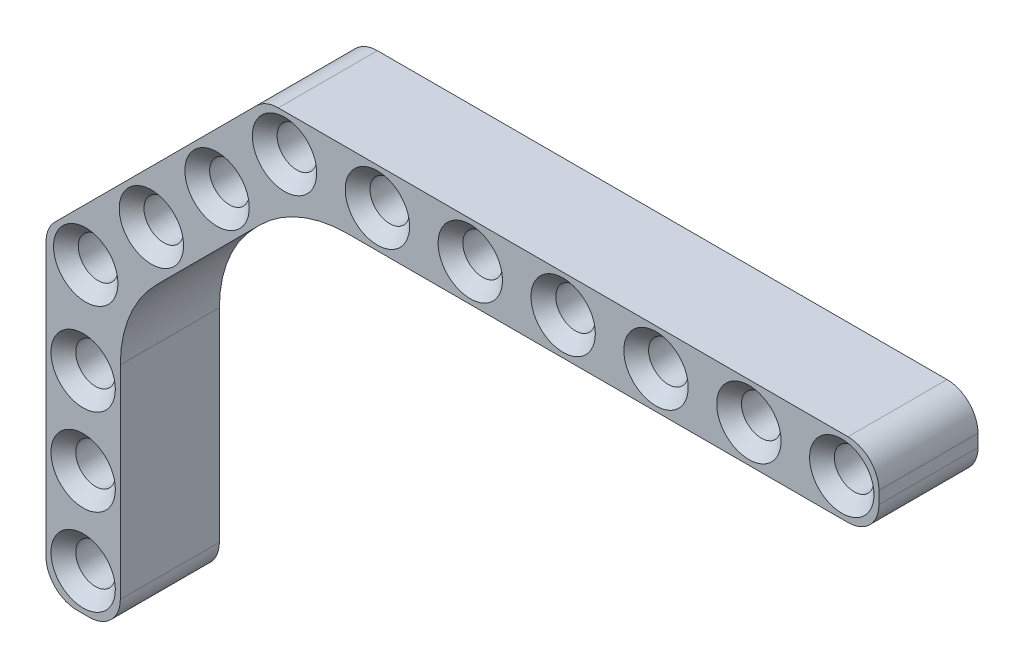
from build123d import *

# Parameters (mm, degrees)
SKETCH1_R           = 1.6
BOSS_EXTRUDE1_DEPTH = 8
CHAMFER1_SIZE       = 1
SKETCH2_R           = 1.6
BOSS_EXTRUDE3_DEPTH = 8
FILLET1_R           = 10
CHAMFER2_SIZE       = 1
CHAMFER3_SIZE       = 1
SKETCH3_R           = 1.6
BOSS_EXTRUDE4_DEPTH = 8
CHAMFER5_SIZE       = 1
FILLET2_R           = 10


with BuildPart() as part:
    # Sketch1 → Boss-Extrude1 (new body)
    with BuildSketch(Plane.XY):
        with BuildLine():
            Line((-0.5, 3), (45.5, 3))
            ThreePointArc((45.5, 3), (47.267766953, 2.267766953), (48, 0.5))
            Line((48, 0.5), (48, -0.5))
            ThreePointArc((48, -0.5), (47.267766953, -2.267766953), (45.5, -3))
            Line((45.5, -3), (-0.5, -3))
            ThreePointArc((-0.5, -3), (-2.267766953, -2.267766953), (-3, -0.5))
            Line((-3, -0.5), (-3, 0.5))
            ThreePointArc((-3, 0.5), (-2.267766953, 2.267766953), (-0.5, 3))
        make_face()
        Circle(SKETCH1_R, mode=Mode.SUBTRACT)
        with Locations((7.5, 0)):
            Circle(SKETCH1_R, mode=Mode.SUBTRACT)
        with Locations((15, 0)):
            Circle(SKETCH1_R, mode=Mode.SUBTRACT)
        with Locations((22.5, 0)):
            Circle(SKETCH1_R, mode=Mode.SUBTRACT)
        with Locations((30, 0)):
            Circle(SKETCH1_R, mode=Mode.SUBTRACT)
        with Locations((37.5, 0)):
            Circle(SKETCH1_R, mode=Mode.SUBTRACT)
        with Locations((45, 0)):
            Circle(SKETCH1_R, mode=Mode.SUBTRACT)
    extrude(amount=BOSS_EXTRUDE1_DEPTH)

    # Chamfer1
    chamfer1_edges = [part.edges().sort_by_distance(p)[0] for p in [
        (-1.6, 0, 0),
        (-1.6, 0, 8),
        (5.9, 0, 0),
        (5.9, 0, 8),
        (13.4, 0, 0),
        (13.4, 0, 8),
        (20.9, 0, 0),
        (20.9, 0, 8),
        (28.4, 0, 0),
        (28.4, 0, 8),
    ]]
    chamfer(chamfer1_edges, length=CHAMFER1_SIZE)

    # Sketch2 → Boss-Extrude3 (add)
    with BuildSketch(Plane.XY.offset(8)):
        with BuildLine():
            ThreePointArc((-3, 0.5), (-2.809698831, 1.456708581), (-2.267766953, 2.267766953))
            Line((-2.267766953, 2.267766953), (-18.529200529, -13.993666623))
            ThreePointArc((-18.529200529, -13.993666623), (-19.261433576, -15.761433576), (-18.529200529, -17.529200529))
            Line((-18.529200529, -17.529200529), (-17.822093748, -18.23630731))
            ThreePointArc((-17.822093748, -18.23630731), (-16.054326795, -18.968540357), (-14.286559842, -18.23630731))
            Line((-14.286559842, -18.23630731), (0.949747468, -3))
            Line((0.949747468, -3), (-0.5, -3))
            ThreePointArc((-0.5, -3), (-2.267766953, -2.267766953), (-3, -0.5))
            Line((-3, -0.5), (-3, 0.5))
        make_face()
        with Locations((-16.054326795, -15.761433576)):
            Circle(SKETCH2_R, mode=Mode.SUBTRACT)
        with Locations((-10.751025936, -10.458132717)):
            Circle(SKETCH2_R, mode=Mode.SUBTRACT)
        with Locations((-5.447725077, -5.154831858)):
            Circle(SKETCH2_R, mode=Mode.SUBTRACT)
    extrude(amount=-BOSS_EXTRUDE3_DEPTH)

    # Fillet1
    fillet1_edges = [part.edges().sort_by_distance(p)[0] for p in [
        (0.949747468, -3, 4),
    ]]
    fillet(fillet1_edges, radius=FILLET1_R)

    # Chamfer2
    chamfer2_edges = [part.edges().sort_by_distance(p)[0] for p in [
        (-17.654326795, -15.761433576, 8),
        (-12.351025936, -10.458132717, 8),
        (-7.047725077, -5.154831858, 8),
        (-7.047725077, -5.154831858, 0),
        (-12.351025936, -10.458132717, 0),
        (-17.654326795, -15.761433576, 0),
    ]]
    chamfer(chamfer2_edges, length=CHAMFER2_SIZE)

    # Chamfer3
    chamfer3_edges = [part.edges().sort_by_distance(p)[0] for p in [
        (35.9, 0, 0),
        (35.9, 0, 8),
        (43.4, 0, 0),
        (43.4, 0, 8),
    ]]
    chamfer(chamfer3_edges, length=CHAMFER3_SIZE)

    # Sketch3 → Boss-Extrude4 (add)
    with BuildSketch(Plane.XY.offset(8)):
        with BuildLine():
            ThreePointArc((-18.529200529, -17.529200529), (-19.071132407, -16.718142157), (-19.261433576, -15.761433576))
            Line((-19.261433576, -15.761433576), (-19.261433576, -37.761433576))
            ThreePointArc((-19.261433576, -37.761433576), (-18.529200529, -39.529200529), (-16.761433576, -40.261433576))
            Line((-16.761433576, -40.261433576), (-15.761433576, -40.261433576))
            ThreePointArc((-15.761433576, -40.261433576), (-13.993666623, -39.529200529), (-13.261433576, -37.761433576))
            Line((-13.261433576, -37.761433576), (-13.261433576, -17.211181044))
            Line((-13.261433576, -17.211181044), (-14.286559842, -18.23630731))
            ThreePointArc((-14.286559842, -18.23630731), (-16.054326795, -18.968540357), (-17.822093748, -18.23630731))
            Line((-17.822093748, -18.23630731), (-18.529200529, -17.529200529))
        make_face()
        with Locations((-16.261433576, -30.261433576)):
            Circle(SKETCH3_R, mode=Mode.SUBTRACT)
        with Locations((-16.261433576, -37.261433576)):
            Circle(SKETCH3_R, mode=Mode.SUBTRACT)
        with Locations((-16.261433576, -23.261433576)):
            Circle(SKETCH3_R, mode=Mode.SUBTRACT)
    extrude(amount=-BOSS_EXTRUDE4_DEPTH)

    # Chamfer5
    chamfer5_edges = [part.edges().sort_by_distance(p)[0] for p in [
        (-17.861433576, -37.261433576, 8),
        (-17.861433576, -30.261433576, 8),
        (-17.861433576, -23.261433576, 8),
        (-17.861433576, -23.261433576, 0),
        (-17.861433576, -30.261433576, 0),
        (-17.861433576, -37.261433576, 0),
    ]]
    chamfer(chamfer5_edges, length=CHAMFER5_SIZE)

    # Fillet2
    fillet2_edges = [part.edges().sort_by_distance(p)[0] for p in [
        (-13.261433576, -17.211181044, 4),
    ]]
    fillet(fillet2_edges, radius=FILLET2_R)


solid = part.part
